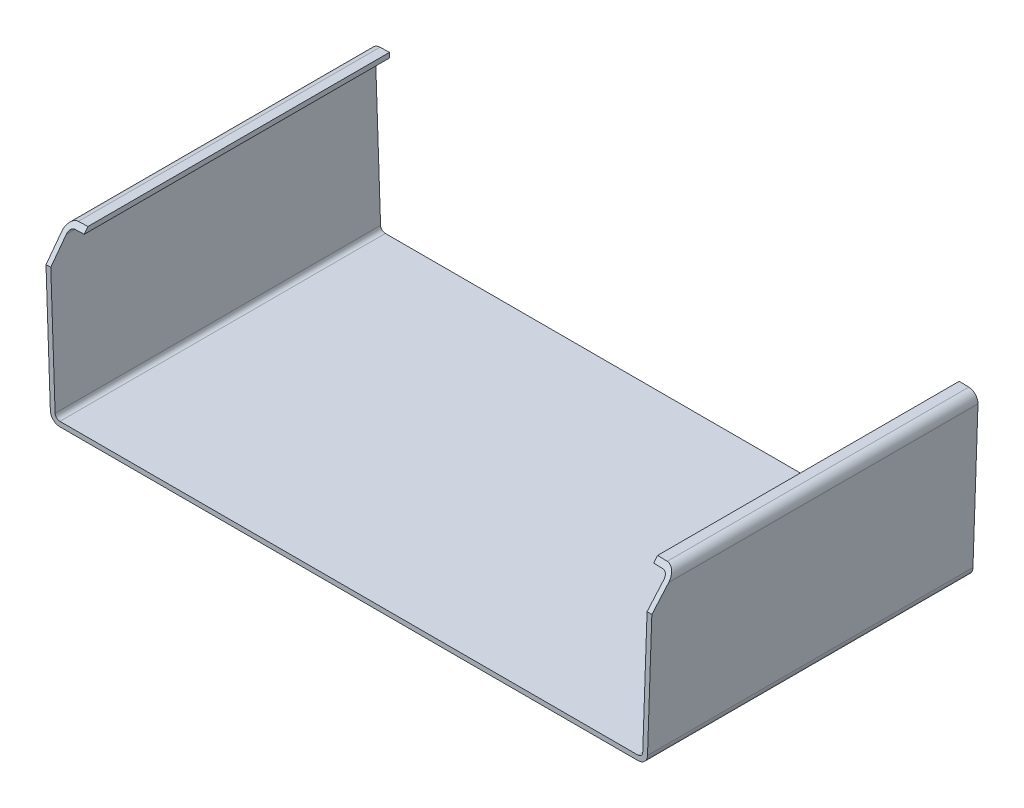
from build123d import *

# Parameters (mm, degrees)
BOSS_EXTRUDE1_DEPTH = 34.1
CUT_EXTRUDE1_DEPTH  = 7


with BuildPart() as part:
    # Sketch1 → Boss-Extrude1 (new body, symmetric)
    with BuildSketch(Plane.XY):
        with BuildLine():
            Line((0, 0), (-60.568627866, 0))
            ThreePointArc((-60.568627866, 0), (-61.957942591, 0.561318453), (-62.567409324, 1.930195406))
            Line((-62.567409324, 1.930195406), (-63.623195406, 32.161524241))
            ThreePointArc((-63.623195406, 32.161524241), (-63.087125173, 33.595321457), (-61.694218542, 34.230110294))
            Line((-61.694218542, 34.230110294), (-59.693, 34.3))
            Line((-59.693, 34.3), (-59.658097703, 33.300609271))
            Line((-59.658097703, 33.300609271), (-61.659316244, 33.230719565))
            ThreePointArc((-61.659316244, 33.230719565), (-62.35576956, 32.913325146), (-62.623804676, 32.196426538))
            Line((-62.623804676, 32.196426538), (-61.568018595, 1.965097703))
            ThreePointArc((-61.568018595, 1.965097703), (-61.263285228, 1.280659226), (-60.568627866, 1))
            Line((-60.568627866, 1), (0, 1))
            Line((0, 1), (60.568627866, 1))
            ThreePointArc((60.568627866, 1), (61.263285228, 1.280659226), (61.568018595, 1.965097703))
            Line((61.568018595, 1.965097703), (62.623804676, 32.196426538))
            ThreePointArc((62.623804676, 32.196426538), (62.35576956, 32.913325146), (61.659316244, 33.230719565))
            Line((61.659316244, 33.230719565), (59.658097703, 33.300609271))
            Line((59.658097703, 33.300609271), (59.693, 34.3))
            Line((59.693, 34.3), (61.694218542, 34.230110294))
            ThreePointArc((61.694218542, 34.230110294), (63.087125173, 33.595321457), (63.623195406, 32.161524241))
            Line((63.623195406, 32.161524241), (62.567409324, 1.930195406))
            ThreePointArc((62.567409324, 1.930195406), (61.957942591, 0.561318453), (60.568627866, 0))
            Line((60.568627866, 0), (0, 0))
        make_face()
    extrude(amount=BOSS_EXTRUDE1_DEPTH, both=True)

    # Sketch2 → Cut-Extrude1 (cut)
    with BuildSketch(Plane(origin=(62.423864353, -2.180064512, 0), x_dir=(0, 0, -1), z_dir=(0.999390729, -0.034902297, 0))):
        Polygon((-34.1, 36.362524836), (-29.1, 36.362524836), (-34.1, 30.162524836), align=None)
    cut_extrude1 = extrude(amount=-CUT_EXTRUDE1_DEPTH, mode=Mode.SUBTRACT)

    # Mirror1: Cut-Extrude1 across plane
    add(cut_extrude1.mirror(Plane(origin=(0, 0, 0), x_dir=(0, 0, 1), z_dir=(1, 0, 0))), mode=Mode.SUBTRACT)


solid = part.part
